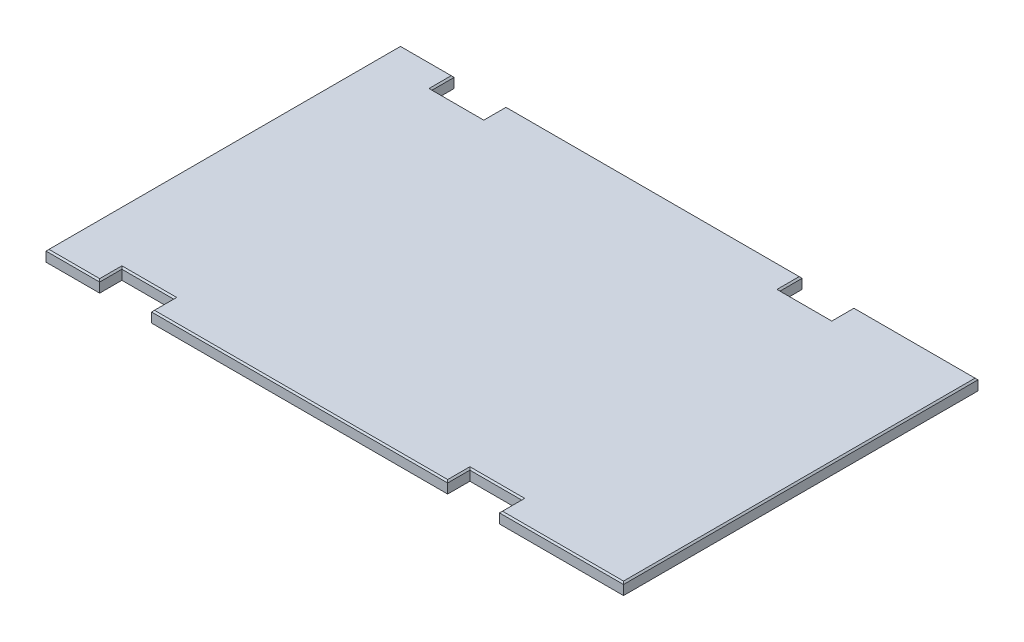
from build123d import *

# Parameters (mm, degrees)
SKETCH1_W           = 990.6
SKETCH1_H           = 608.0125
BOSS_EXTRUDE1_DEPTH = 19.05
SKETCH2_W           = 88.9
SKETCH2_H           = 38.1
CUT_EXTRUDE1_DEPTH  = 20.05
CHAMFER1_SIZE       = 2.54


with BuildPart() as part:
    # Sketch1 → Boss-Extrude1 (new body)
    with BuildSketch(Plane(origin=(0, 0, 0), x_dir=(1, 0, 0), z_dir=(0, 1, 0))):
        with Locations((495.3, 304.00625)):
            Rectangle(SKETCH1_W, SKETCH1_H)
    extrude(amount=BOSS_EXTRUDE1_DEPTH)

    # Sketch2 → Cut-Extrude1 (cut, through all)
    with BuildSketch(Plane(origin=(0, 19.05, 0), x_dir=(1, 0, 0), z_dir=(0, 1, 0))):
        with Locations((733.425, 588.9625)):
            Rectangle(SKETCH2_W, SKETCH2_H)
        with Locations((136.525, 588.9625)):
            Rectangle(SKETCH2_W, SKETCH2_H)
        with Locations((136.525, 19.05)):
            Rectangle(SKETCH2_W, SKETCH2_H)
        with Locations((733.425, 19.05)):
            Rectangle(SKETCH2_W, SKETCH2_H)
    extrude(amount=-CUT_EXTRUDE1_DEPTH, mode=Mode.SUBTRACT)

    # Chamfer1
    chamfer1_edges = [part.edges().sort_by_distance(p)[0] for p in [
        (990.6, 19.05, -304.00625),
        (884.2375, 19.05, -608.0125),
        (434.975, 19.05, 0),
        (884.2375, 19.05, 0),
        (434.975, 19.05, -608.0125),
        (46.0375, 19.05, -608.0125),
        (733.425, 19.05, -38.1),
        (688.975, 19.05, -19.05),
        (777.875, 19.05, -19.05),
        (180.975, 19.05, -19.05),
        (136.525, 19.05, -38.1),
        (92.075, 19.05, -19.05),
        (92.075, 19.05, -588.9625),
        (136.525, 19.05, -569.9125),
        (180.975, 19.05, -588.9625),
        (0, 19.05, -304.00625),
        (777.875, 19.05, -588.9625),
        (688.975, 19.05, -588.9625),
        (733.425, 19.05, -569.9125),
        (46.0375, 19.05, 0),
    ]]
    chamfer(chamfer1_edges, length=CHAMFER1_SIZE)


solid = part.part
